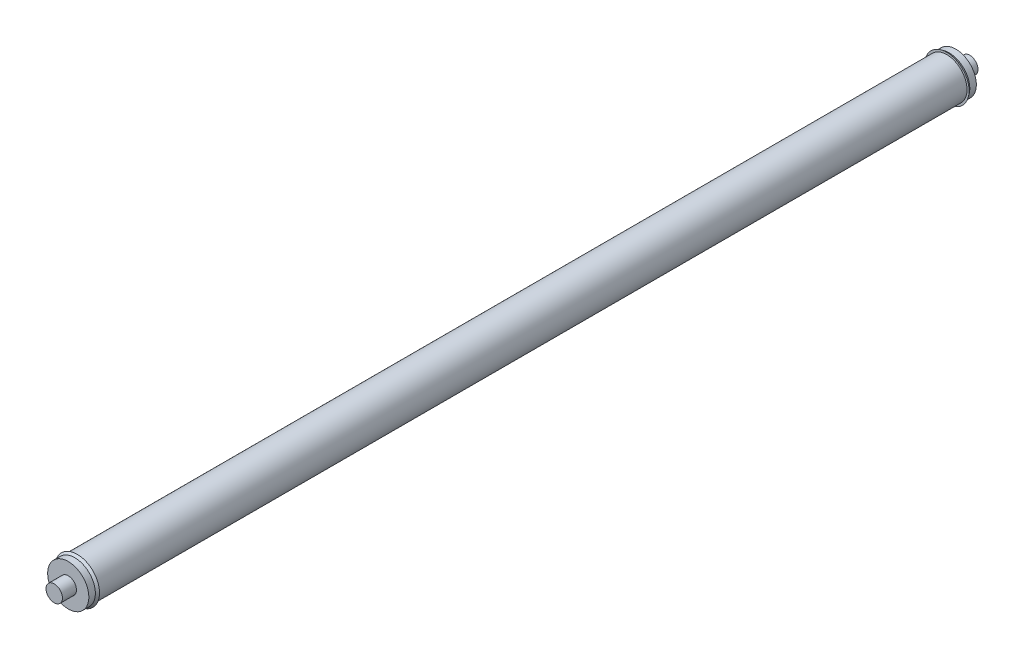
from build123d import *


with BuildPart() as part:
    # Sketch1 → Revolve1 (revolve)
    with BuildSketch(Plane(origin=(0, 0, 0), x_dir=(1, 0, 0), z_dir=(0, 1, 0))):
        Polygon((0, 56.5), (0, 54.77), (0, -54.77), (0, -56.5), (1.015, -56.5), (1.015, -54.77), (2.54, -54.77), (2.54, -53.96), (2.75, -53.66), (2.5, -53.66), (2.5, 53.66), (2.75, 53.66), (2.54, 53.96), (2.54, 54.77), (1.015, 54.77), (1.015, 56.5), align=None)
    revolve(axis=Axis((0, 0, -71.413911165), (0, 0, 1)))


solid = part.part
